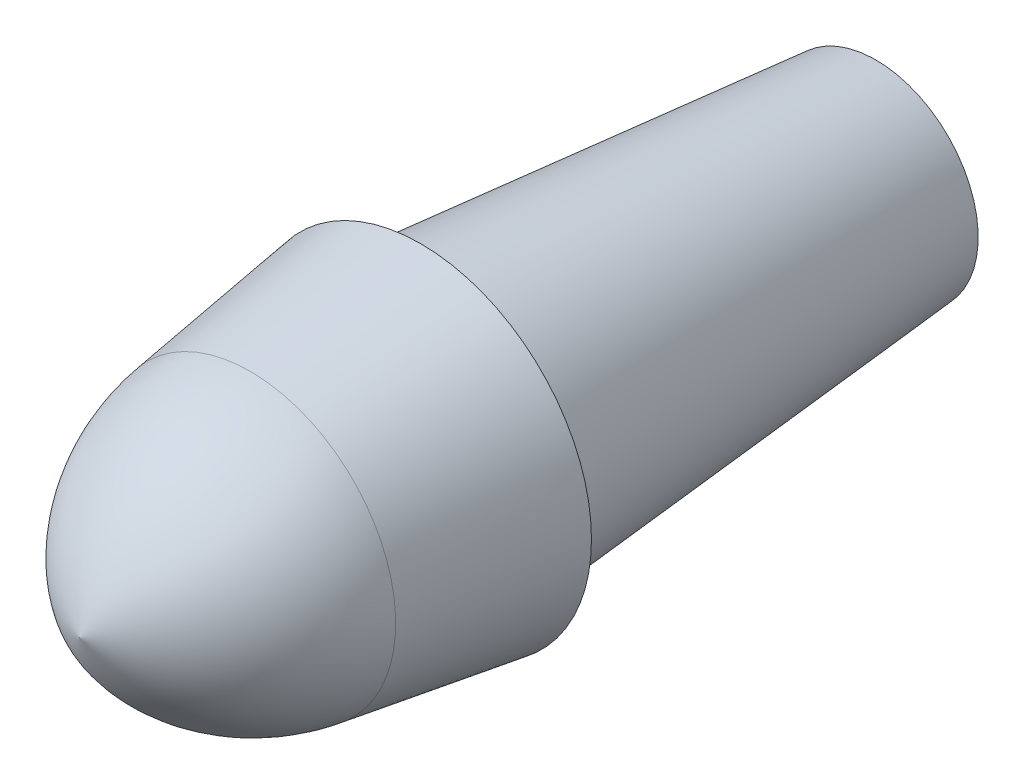
from build123d import *

# Parameters (mm, degrees)
SKETCH2_R = 6.25
SKETCH4_R = 4.5


with BuildPart() as part:
    # Sketch1 → Revolve1 (revolve)
    with BuildSketch(Plane(origin=(0, 0, 0), x_dir=(1, 0, 0), z_dir=(0, 1, 0))):
        with BuildLine():
            Line((0, 0), (-7.5, 0))
            Line((-7.5, 0), (-6.39268212, -7.5))
            ThreePointArc((-6.39268212, -7.5), (-4.273203785, -12.167872145), (0, -15))
            Line((0, -15), (0, 0))
        make_face()
    revolve(axis=Axis((0, 0, 0), (0, 0, 1)))

    # Sketch2 → Loft2 section 0
    with BuildSketch(Plane(origin=(0, 0, 0), x_dir=(-1, 0, 0), z_dir=(0, 0, -1))):
        Circle(SKETCH2_R)
    # Sketch4 → Loft2 section 1
    with BuildSketch(Plane(origin=(0, 0, -20), x_dir=(-1, 0, 0), z_dir=(0, 0, -1))):
        Circle(SKETCH4_R)
    loft()


solid = part.part
